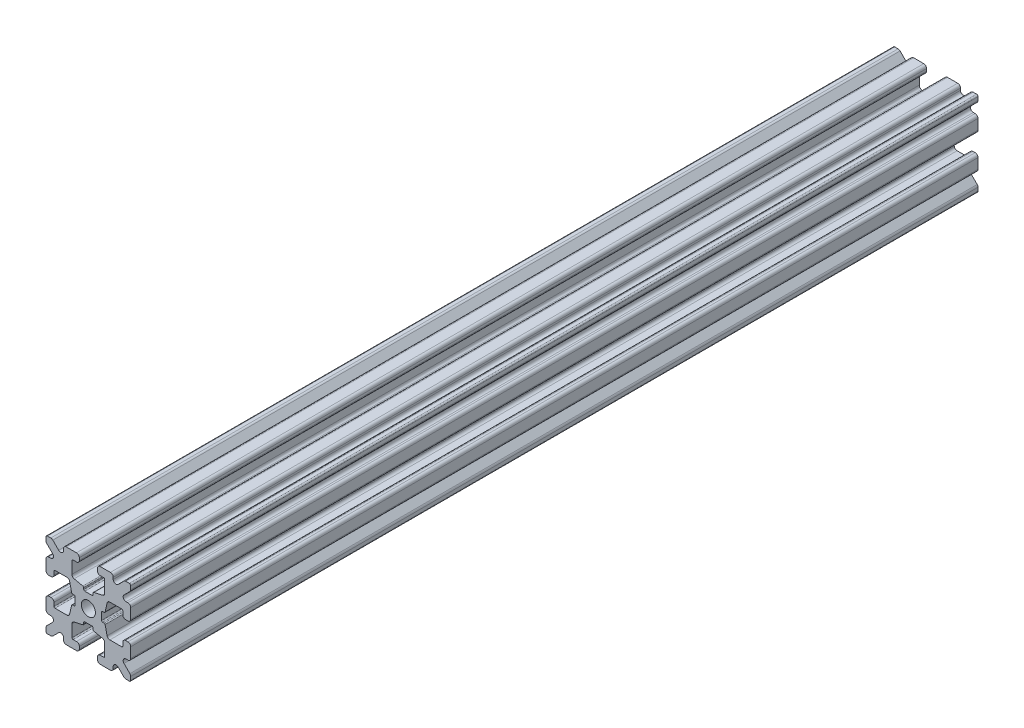
from build123d import *

# Parameters (mm, degrees)
PROFILE_R           = 1.25
BOSS_EXTRUDE1_DEPTH = 150


with BuildPart() as part:
    # Profile → Boss-Extrude1 (new body)
    with BuildSketch(Plane.XY):
        with BuildLine():
            Line((0.6255, -2.3470646), (-0.6255, -2.3470646))
            ThreePointArc((-0.6255, -2.3470646), (-0.766921356, -2.405643244), (-0.8255, -2.5470646))
            Line((-0.8255, -2.5470646), (-0.8255, -2.774891226))
            ThreePointArc((-0.8255, -2.774891226), (-0.869377519, -2.89989431), (-0.981757709, -2.970049142))
            Line((-0.981757709, -2.970049142), (-2.509355729, -3.312441801))
            ThreePointArc((-2.509355729, -3.312441801), (-2.790306203, -3.487828881), (-2.9, -3.80033659))
            Line((-2.9, -3.80033659), (-2.9, -5.9))
            ThreePointArc((-2.9, -5.9), (-2.841421356, -6.041421356), (-2.7, -6.1))
            Line((-2.7, -6.1), (-2.1, -6.1))
            ThreePointArc((-2.1, -6.1), (-1.746446609, -6.246446609), (-1.6, -6.6))
            Line((-1.6, -6.6), (-1.6, -7))
            ThreePointArc((-1.6, -7), (-1.746446609, -7.353553391), (-2.1, -7.5))
            Line((-2.1, -7.5), (-3.9, -7.5))
            ThreePointArc((-3.9, -7.5), (-4.253553391, -7.353553391), (-4.4, -7))
            Line((-4.4, -7), (-4.4, -6.667766953))
            ThreePointArc((-4.4, -6.667766953), (-4.708658284, -6.205827187), (-5.253553391, -6.314213562))
            Line((-5.253553391, -6.314213562), (-6.292893219, -7.353553391))
            ThreePointArc((-6.292893219, -7.353553391), (-6.455104893, -7.461939766), (-6.646446609, -7.5))
            Line((-6.646446609, -7.5), (-7.25, -7.5))
            ThreePointArc((-7.25, -7.5), (-7.426776695, -7.426776695), (-7.5, -7.25))
            Line((-7.5, -7.25), (-7.5, -6.646446609))
            ThreePointArc((-7.5, -6.646446609), (-7.461939766, -6.455104893), (-7.353553391, -6.292893219))
            Line((-7.353553391, -6.292893219), (-6.314213562, -5.253553391))
            ThreePointArc((-6.314213562, -5.253553391), (-6.205827187, -4.708658284), (-6.667766953, -4.4))
            Line((-6.667766953, -4.4), (-7, -4.4))
            ThreePointArc((-7, -4.4), (-7.353553391, -4.253553391), (-7.5, -3.9))
            Line((-7.5, -3.9), (-7.5, -2.1))
            ThreePointArc((-7.5, -2.1), (-7.353553391, -1.746446609), (-7, -1.6))
            Line((-7, -1.6), (-6.6, -1.6))
            ThreePointArc((-6.6, -1.6), (-6.246446609, -1.746446609), (-6.1, -2.1))
            Line((-6.1, -2.1), (-6.1, -2.7))
            ThreePointArc((-6.1, -2.7), (-6.041421356, -2.841421356), (-5.9, -2.9))
            Line((-5.9, -2.9), (-3.80033659, -2.9))
            ThreePointArc((-3.80033659, -2.9), (-3.487828881, -2.790306203), (-3.312441801, -2.509355728))
            Line((-3.312441801, -2.509355728), (-2.970049142, -0.981757709))
            ThreePointArc((-2.970049142, -0.981757709), (-2.89989431, -0.869377519), (-2.774891226, -0.8255))
            Line((-2.774891226, -0.8255), (-2.5470646, -0.8255))
            ThreePointArc((-2.5470646, -0.8255), (-2.405643244, -0.766921356), (-2.3470646, -0.6255))
            Line((-2.3470646, -0.6255), (-2.3470646, 0.6255))
            ThreePointArc((-2.3470646, 0.6255), (-2.405643244, 0.766921356), (-2.5470646, 0.8255))
            Line((-2.5470646, 0.8255), (-2.774891226, 0.8255))
            ThreePointArc((-2.774891226, 0.8255), (-2.89989431, 0.869377519), (-2.970049142, 0.981757709))
            Line((-2.970049142, 0.981757709), (-3.312441801, 2.509355729))
            ThreePointArc((-3.312441801, 2.509355729), (-3.487828881, 2.790306203), (-3.80033659, 2.9))
            Line((-3.80033659, 2.9), (-5.9, 2.9))
            ThreePointArc((-5.9, 2.9), (-6.041421356, 2.841421356), (-6.1, 2.7))
            Line((-6.1, 2.7), (-6.1, 2.1))
            ThreePointArc((-6.1, 2.1), (-6.246446609, 1.746446609), (-6.6, 1.6))
            Line((-6.6, 1.6), (-7, 1.6))
            ThreePointArc((-7, 1.6), (-7.353553391, 1.746446609), (-7.5, 2.1))
            Line((-7.5, 2.1), (-7.5, 3.9))
            ThreePointArc((-7.5, 3.9), (-7.353553391, 4.253553391), (-7, 4.4))
            Line((-7, 4.4), (-6.667766953, 4.4))
            ThreePointArc((-6.667766953, 4.4), (-6.205827187, 4.708658284), (-6.314213562, 5.253553391))
            Line((-6.314213562, 5.253553391), (-7.353553391, 6.292893219))
            ThreePointArc((-7.353553391, 6.292893219), (-7.461939766, 6.455104893), (-7.5, 6.646446609))
            Line((-7.5, 6.646446609), (-7.5, 7.25))
            ThreePointArc((-7.5, 7.25), (-7.426776695, 7.426776695), (-7.25, 7.5))
            Line((-7.25, 7.5), (-6.646446609, 7.5))
            ThreePointArc((-6.646446609, 7.5), (-6.455104893, 7.461939766), (-6.292893219, 7.353553391))
            Line((-6.292893219, 7.353553391), (-5.253553391, 6.314213562))
            ThreePointArc((-5.253553391, 6.314213562), (-4.708658284, 6.205827187), (-4.4, 6.667766953))
            Line((-4.4, 6.667766953), (-4.4, 7))
            ThreePointArc((-4.4, 7), (-4.253553391, 7.353553391), (-3.9, 7.5))
            Line((-3.9, 7.5), (-2.1, 7.5))
            ThreePointArc((-2.1, 7.5), (-1.746446609, 7.353553391), (-1.6, 7))
            Line((-1.6, 7), (-1.6, 6.6))
            ThreePointArc((-1.6, 6.6), (-1.746446609, 6.246446609), (-2.1, 6.1))
            Line((-2.1, 6.1), (-2.7, 6.1))
            ThreePointArc((-2.7, 6.1), (-2.841421356, 6.041421356), (-2.9, 5.9))
            Line((-2.9, 5.9), (-2.9, 3.80033659))
            ThreePointArc((-2.9, 3.80033659), (-2.790306203, 3.487828881), (-2.509355728, 3.312441801))
            Line((-2.509355728, 3.312441801), (-0.981757709, 2.970049142))
            ThreePointArc((-0.981757709, 2.970049142), (-0.869377519, 2.89989431), (-0.8255, 2.774891226))
            Line((-0.8255, 2.774891226), (-0.8255, 2.5470646))
            ThreePointArc((-0.8255, 2.5470646), (-0.766921356, 2.405643244), (-0.6255, 2.3470646))
            Line((-0.6255, 2.3470646), (0.6255, 2.3470646))
            ThreePointArc((0.6255, 2.3470646), (0.766921356, 2.405643244), (0.8255, 2.5470646))
            Line((0.8255, 2.5470646), (0.8255, 2.774891226))
            ThreePointArc((0.8255, 2.774891226), (0.869377519, 2.89989431), (0.981757709, 2.970049142))
            Line((0.981757709, 2.970049142), (2.509355728, 3.312441801))
            ThreePointArc((2.509355728, 3.312441801), (2.790306203, 3.487828881), (2.9, 3.80033659))
            Line((2.9, 3.80033659), (2.9, 5.9))
            ThreePointArc((2.9, 5.9), (2.841421356, 6.041421356), (2.7, 6.1))
            Line((2.7, 6.1), (2.1, 6.1))
            ThreePointArc((2.1, 6.1), (1.746446609, 6.246446609), (1.6, 6.6))
            Line((1.6, 6.6), (1.6, 7))
            ThreePointArc((1.6, 7), (1.746446609, 7.353553391), (2.1, 7.5))
            Line((2.1, 7.5), (3.9, 7.5))
            ThreePointArc((3.9, 7.5), (4.253553391, 7.353553391), (4.4, 7))
            Line((4.4, 7), (4.4, 6.667766953))
            ThreePointArc((4.4, 6.667766953), (4.708658284, 6.205827187), (5.253553391, 6.314213562))
            Line((5.253553391, 6.314213562), (6.292893219, 7.353553391))
            ThreePointArc((6.292893219, 7.353553391), (6.455104893, 7.461939766), (6.646446609, 7.5))
            Line((6.646446609, 7.5), (7.25, 7.5))
            ThreePointArc((7.25, 7.5), (7.426776695, 7.426776695), (7.5, 7.25))
            Line((7.5, 7.25), (7.5, 6.646446609))
            ThreePointArc((7.5, 6.646446609), (7.461939766, 6.455104893), (7.353553391, 6.292893219))
            Line((7.353553391, 6.292893219), (6.314213562, 5.253553391))
            ThreePointArc((6.314213562, 5.253553391), (6.205827187, 4.708658284), (6.667766953, 4.4))
            Line((6.667766953, 4.4), (7, 4.4))
            ThreePointArc((7, 4.4), (7.353553391, 4.253553391), (7.5, 3.9))
            Line((7.5, 3.9), (7.5, 2.1))
            ThreePointArc((7.5, 2.1), (7.353553391, 1.746446609), (7, 1.6))
            Line((7, 1.6), (6.6, 1.6))
            ThreePointArc((6.6, 1.6), (6.246446609, 1.746446609), (6.1, 2.1))
            Line((6.1, 2.1), (6.1, 2.7))
            ThreePointArc((6.1, 2.7), (6.041421356, 2.841421356), (5.9, 2.9))
            Line((5.9, 2.9), (3.80033659, 2.9))
            ThreePointArc((3.80033659, 2.9), (3.487828881, 2.790306203), (3.312441801, 2.509355728))
            Line((3.312441801, 2.509355728), (2.970049142, 0.981757709))
            ThreePointArc((2.970049142, 0.981757709), (2.89989431, 0.869377519), (2.774891226, 0.8255))
            Line((2.774891226, 0.8255), (2.5470646, 0.8255))
            ThreePointArc((2.5470646, 0.8255), (2.405643244, 0.766921356), (2.3470646, 0.6255))
            Line((2.3470646, 0.6255), (2.3470646, -0.6255))
            ThreePointArc((2.3470646, -0.6255), (2.405643244, -0.766921356), (2.5470646, -0.8255))
            Line((2.5470646, -0.8255), (2.774891226, -0.8255))
            ThreePointArc((2.774891226, -0.8255), (2.89989431, -0.869377519), (2.970049142, -0.981757709))
            Line((2.970049142, -0.981757709), (3.312441801, -2.509355728))
            ThreePointArc((3.312441801, -2.509355728), (3.487828881, -2.790306203), (3.80033659, -2.9))
            Line((3.80033659, -2.9), (5.9, -2.9))
            ThreePointArc((5.9, -2.9), (6.041421356, -2.841421356), (6.1, -2.7))
            Line((6.1, -2.7), (6.1, -2.1))
            ThreePointArc((6.1, -2.1), (6.246446609, -1.746446609), (6.6, -1.6))
            Line((6.6, -1.6), (7, -1.6))
            ThreePointArc((7, -1.6), (7.353553391, -1.746446609), (7.5, -2.1))
            Line((7.5, -2.1), (7.5, -3.9))
            ThreePointArc((7.5, -3.9), (7.353553391, -4.253553391), (7, -4.4))
            Line((7, -4.4), (6.667766953, -4.4))
            ThreePointArc((6.667766953, -4.4), (6.205827187, -4.708658284), (6.314213562, -5.253553391))
            Line((6.314213562, -5.253553391), (7.353553391, -6.292893219))
            ThreePointArc((7.353553391, -6.292893219), (7.461939766, -6.455104893), (7.5, -6.646446609))
            Line((7.5, -6.646446609), (7.5, -7.25))
            ThreePointArc((7.5, -7.25), (7.426776695, -7.426776695), (7.25, -7.5))
            Line((7.25, -7.5), (6.646446609, -7.5))
            ThreePointArc((6.646446609, -7.5), (6.455104893, -7.461939766), (6.292893219, -7.353553391))
            Line((6.292893219, -7.353553391), (5.253553391, -6.314213562))
            ThreePointArc((5.253553391, -6.314213562), (4.708658284, -6.205827187), (4.4, -6.667766953))
            Line((4.4, -6.667766953), (4.4, -7))
            ThreePointArc((4.4, -7), (4.253553391, -7.353553391), (3.9, -7.5))
            Line((3.9, -7.5), (2.1, -7.5))
            ThreePointArc((2.1, -7.5), (1.746446609, -7.353553391), (1.6, -7))
            Line((1.6, -7), (1.6, -6.6))
            ThreePointArc((1.6, -6.6), (1.746446609, -6.246446609), (2.1, -6.1))
            Line((2.1, -6.1), (2.7, -6.1))
            ThreePointArc((2.7, -6.1), (2.841421356, -6.041421356), (2.9, -5.9))
            Line((2.9, -5.9), (2.9, -3.80033659))
            ThreePointArc((2.9, -3.80033659), (2.790306203, -3.487828881), (2.509355728, -3.312441801))
            Line((2.509355728, -3.312441801), (0.981757709, -2.970049142))
            ThreePointArc((0.981757709, -2.970049142), (0.869377519, -2.89989431), (0.8255, -2.774891226))
            Line((0.8255, -2.774891226), (0.8255, -2.5470646))
            ThreePointArc((0.8255, -2.5470646), (0.766921356, -2.405643244), (0.6255, -2.3470646))
        make_face()
        Circle(PROFILE_R, mode=Mode.SUBTRACT)
    extrude(amount=-BOSS_EXTRUDE1_DEPTH)


solid = part.part
